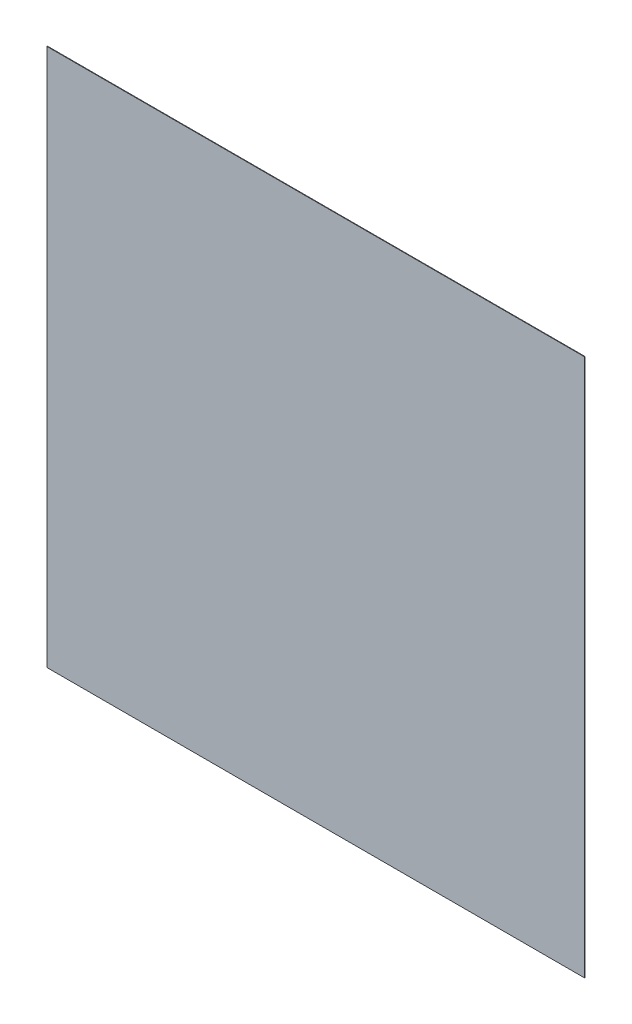
from build123d import *

# Parameters (mm, degrees)
ESQUISSE1_W        = 10000
ESQUISSE1_H        = 10000
BOSS_EXTRU_1_DEPTH = 10


with BuildPart() as part:
    # Esquisse1 → Boss.-Extru.1 (new body)
    with BuildSketch(Plane.XY):
        Rectangle(ESQUISSE1_W, ESQUISSE1_H)
    extrude(amount=BOSS_EXTRU_1_DEPTH)


solid = part.part
